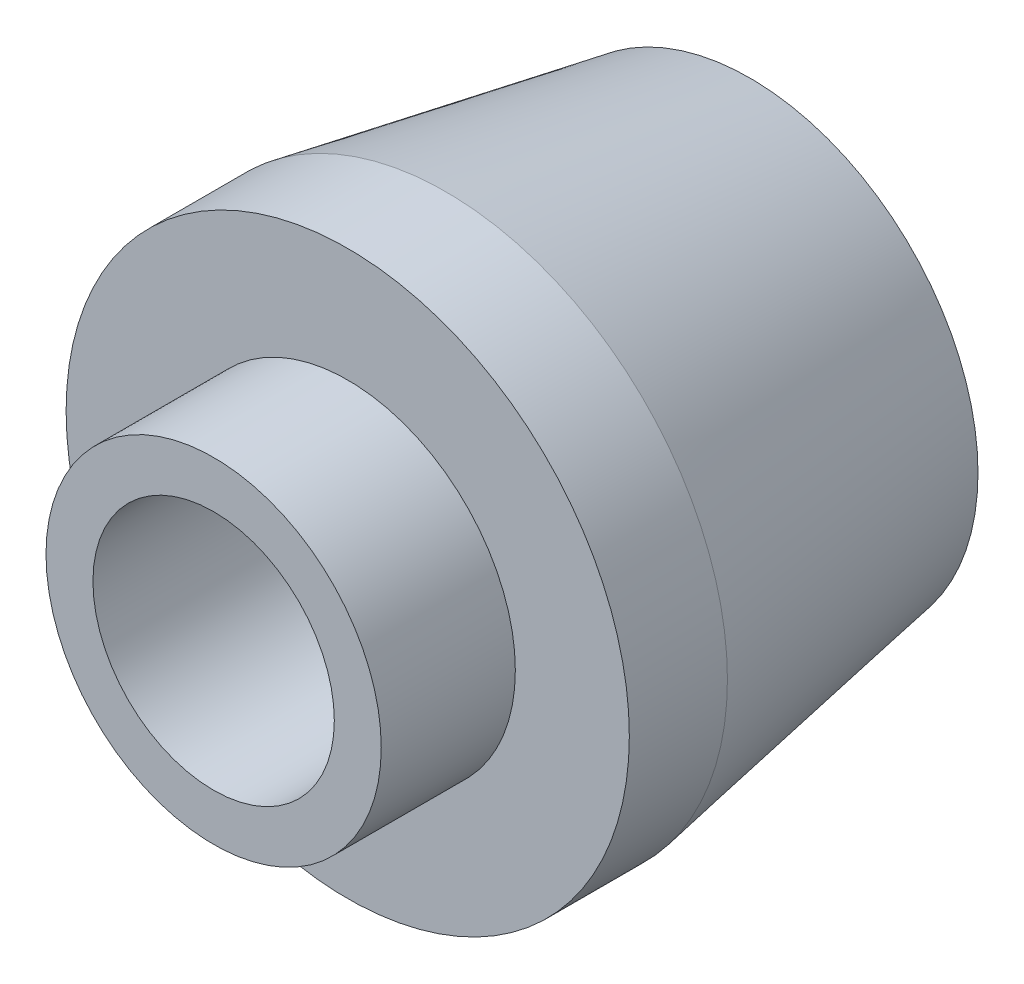
from build123d import *

# Parameters (mm, degrees)
SKETCH1_R                        = 10.5
BOSS_EXTRUDE1_DEPTH              = 15
SKETCH2_R                        = 6.25
BOSS_EXTRUDE2_DEPTH              = 5
M10X1_0_TAPPED_HOLE1_D           = 9
M10X1_0_TAPPED_HOLE1_CSINK_D     = 10.05
M10X1_0_TAPPED_HOLE1_CSINK_ANGLE = 90
CHAMFER1_SIZE                    = 2
CHAMFER1_SIZE2                   = 11.342563639


with BuildPart() as part:
    # Sketch1 → Boss-Extrude1 (new body)
    with BuildSketch(Plane.XY):
        Circle(SKETCH1_R)
    extrude(amount=BOSS_EXTRUDE1_DEPTH)

    # Sketch2 → Boss-Extrude2 (add)
    with BuildSketch(Plane.XY.offset(15)):
        Circle(SKETCH2_R)
    extrude(amount=BOSS_EXTRUDE2_DEPTH)

    # M10x1.0 Tapped Hole1 (through all)
    with Locations(Plane(origin=(0, 0, 0), x_dir=(-1, 0, 0), z_dir=(0, 0, -1))):
        with Locations((0, 0)):
            CounterSinkHole(M10X1_0_TAPPED_HOLE1_D / 2, M10X1_0_TAPPED_HOLE1_CSINK_D / 2, counter_sink_angle=M10X1_0_TAPPED_HOLE1_CSINK_ANGLE)

    # Chamfer1
    chamfer1_edges = [part.edges().sort_by_distance(p)[0] for p in [
        (-10.5, 0, 0),
    ]]
    chamfer1_side = [part.faces().sort_by_distance(p)[0] for p in [
        (-10.203015152, 0, 0),
    ]]
    chamfer(chamfer1_edges, length=CHAMFER1_SIZE, length2=CHAMFER1_SIZE2, reference=chamfer1_side[0])


solid = part.part
